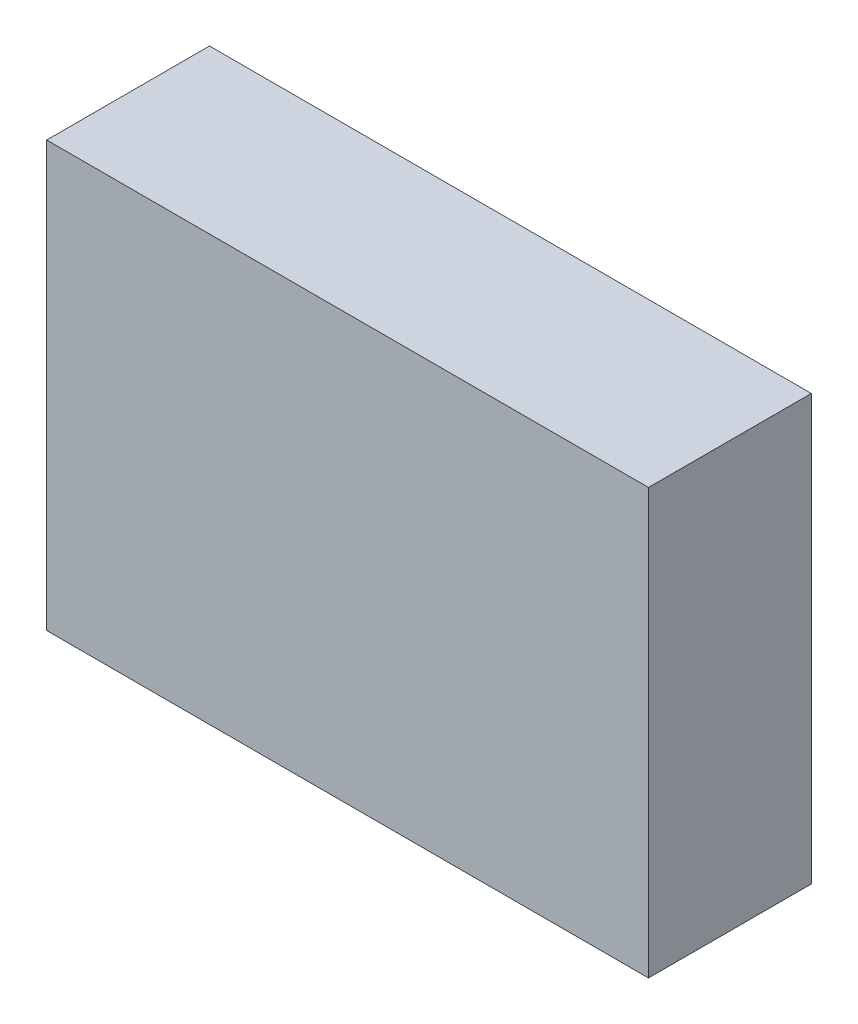
from build123d import *

# Parameters (mm, degrees)
SKETCH_1_W      = 8.5
SKETCH_1_H      = 6
EXTRUDE_1_DEPTH = 2.3


with BuildPart() as part:
    # 草图1 → 凸台-拉伸1 (new body)
    with BuildSketch(Plane.XY):
        with Locations((20.249587155, 12.312648367)):
            Rectangle(SKETCH_1_W, SKETCH_1_H)
    extrude(amount=EXTRUDE_1_DEPTH)


solid = part.part
